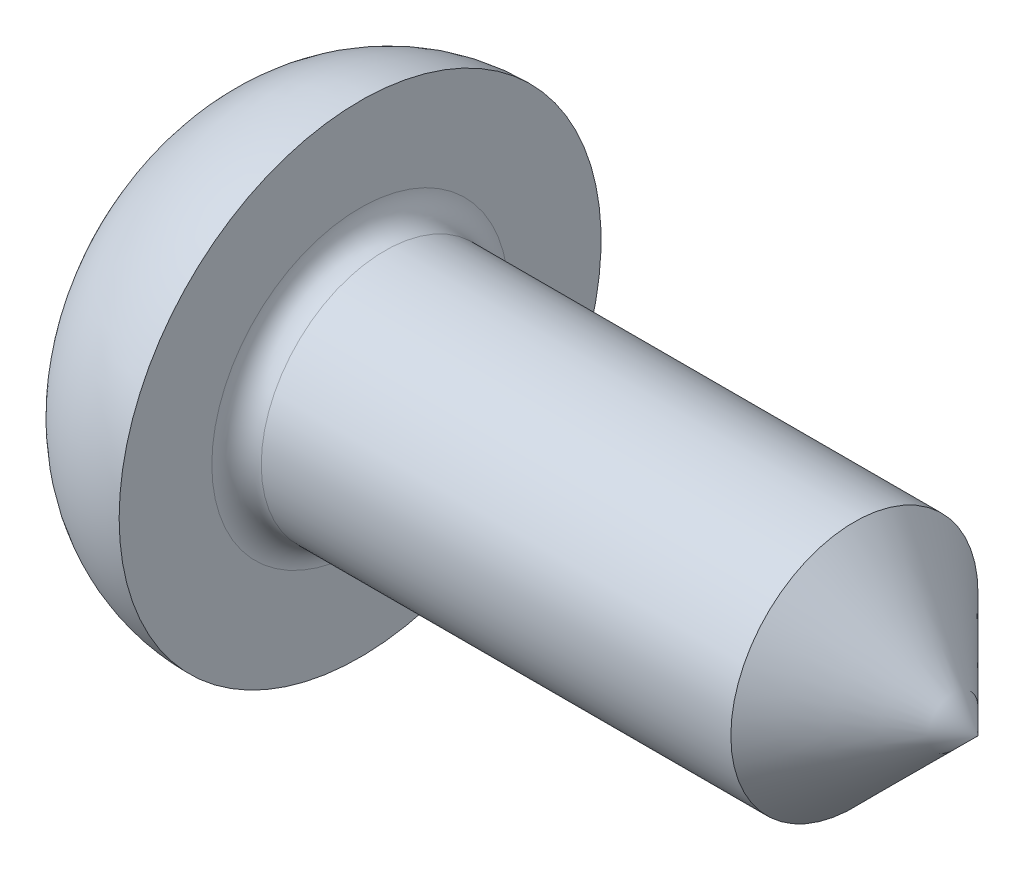
from build123d import *

# Parameters (mm, degrees)
FILLET2_R = 0.2


with BuildPart() as part:
    # Sketch1 → Revolve1 (revolve)
    with BuildSketch(Plane(origin=(0, 0, 0), x_dir=(1, 0, 0), z_dir=(0, 1, 0))):
        with BuildLine():
            Line((1.6, 1), (6.6, 1))
            Line((6.6, 1), (6.6, 0))
            Line((6.6, 0), (0, 0))
            ThreePointArc((0, 0), (0.12318754, 0.742622052), (0.479554358, 1.405694727))
            ThreePointArc((0.479554358, 1.405694727), (0.97590539, 1.809326647), (1.6, 1.95))
            Line((1.6, 1.95), (1.6, 1))
        make_face()
    revolve(axis=Axis((-13.629268293, 0, 0), (1, 0, 0)))

    # Fillet2
    fillet2_edges = [part.edges().sort_by_distance(p)[0] for p in [
        (1.6, 0, 1),
    ]]
    fillet(fillet2_edges, radius=FILLET2_R)

    # Sketch4 → Cut-Revolve1 (revolve, cut)
    with BuildSketch(Plane(origin=(0, 0, 0), x_dir=(1, 0, 0), z_dir=(0, 1, 0))):
        Polygon((7.333454633, 0), (7.333454633, 21), (-14.4, 21), (6.6, 0), align=None)
    revolve(axis=Axis((4.782773752, 0, 0), (1, 0, 0)), mode=Mode.SUBTRACT)

    # Sketch2 → Cut-Loft1 section 0
    with BuildSketch(Plane(origin=(0, 0, 0), x_dir=(0, 0, -1), z_dir=(1, 0, 0)), mode=Mode.PRIVATE) as cut_loft1_s0:
        Polygon((-0.3125, 0.3125), (-1.25, 0.3125), (-1.25, -0.3125), (-0.3125, -0.3125), (-0.3125, -1.25), (0.3125, -1.25), (0.3125, -0.3125), (1.25, -0.3125), (1.25, 0.3125), (0.3125, 0.3125), (0.3125, 1.25), (-0.3125, 1.25), align=None)
    loft([Vertex(1.85, 0, 0), cut_loft1_s0.sketch], mode=Mode.SUBTRACT)


solid = part.part
